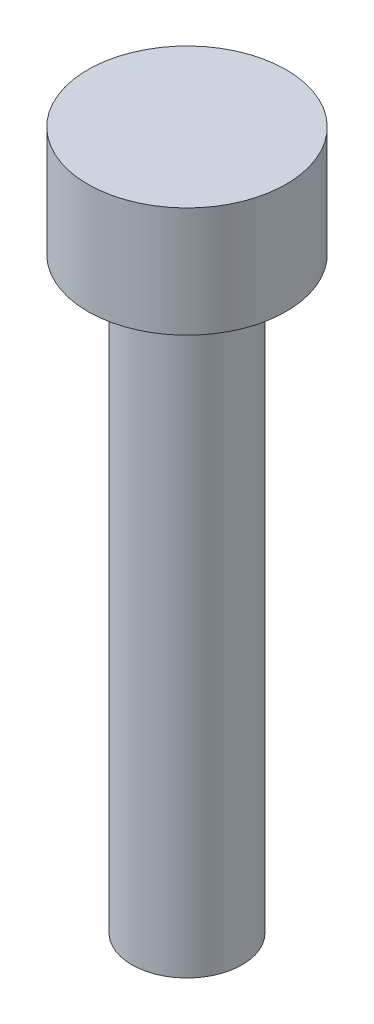
from build123d import *

# Parameters (mm, degrees)
SKETCH1_R           = 1.5
BOSS_EXTRUDE1_DEPTH = 16
SKETCH2_R           = 2.7
BOSS_EXTRUDE2_DEPTH = 3


with BuildPart() as part:
    # Sketch1 → Boss-Extrude1 (new body)
    with BuildSketch(Plane(origin=(0, 0, 0), x_dir=(1, 0, 0), z_dir=(0, 1, 0))):
        Circle(SKETCH1_R)
    extrude(amount=BOSS_EXTRUDE1_DEPTH)

    # Sketch2 → Boss-Extrude2 (add)
    with BuildSketch(Plane(origin=(0, 16, 0), x_dir=(1, 0, 0), z_dir=(0, 1, 0))):
        Circle(SKETCH2_R)
    extrude(amount=BOSS_EXTRUDE2_DEPTH)


solid = part.part
